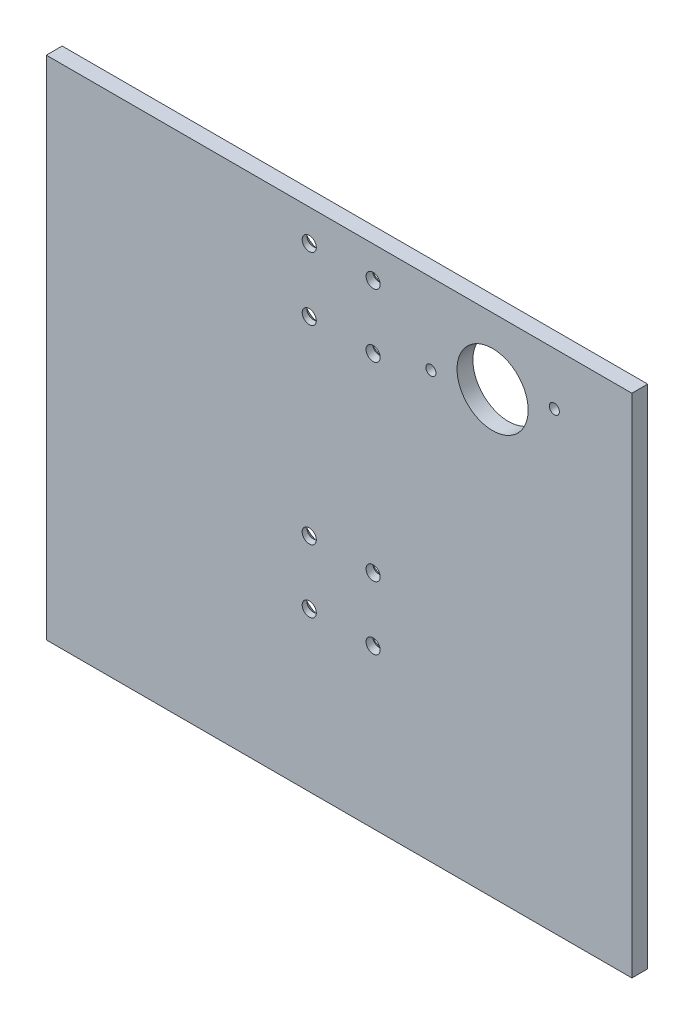
from build123d import *

# Parameters (mm, degrees)
SKETCH1_W                                          = 234.95
SKETCH1_H                                          = 203.2
BOSS_EXTRUDE1_DEPTH                                = 6.35
SKETCH2_R                                          = 14.2748
CUT_EXTRUDE1_DEPTH                                 = 7.35
CSK_FOR_10_FLAT_HEAD_MACHINE_SCREW_100_D           = 5.6134
CSK_FOR_10_FLAT_HEAD_MACHINE_SCREW_100_CSINK_D     = 17.78
CSK_FOR_10_FLAT_HEAD_MACHINE_SCREW_100_CSINK_ANGLE = 90
CSK_FOR_10_FLAT_HEAD_MACHINE_SCREW_2_D             = 5.6134
CSK_FOR_10_FLAT_HEAD_MACHINE_SCREW_2_CSINK_D       = 17.78
CSK_FOR_10_FLAT_HEAD_MACHINE_SCREW_2_CSINK_ANGLE   = 90
CUT_EXTRUDE2_DEPTH                                 = 7.35


with BuildPart() as part:
    # Sketch1 → Boss-Extrude1 (new body)
    with BuildSketch(Plane.XY):
        Rectangle(SKETCH1_W, SKETCH1_H)
    extrude(amount=BOSS_EXTRUDE1_DEPTH)

    # Sketch2 → Cut-Extrude1 (cut, through all)
    with BuildSketch(Plane.XY.offset(6.35)):
        with Locations((61.595, 74.93)):
            Circle(SKETCH2_R)
    extrude(amount=-CUT_EXTRUDE1_DEPTH, mode=Mode.SUBTRACT)

    # CSK for _10 Flat Head Machine Screw _100 (through all)
    with Locations(Plane(origin=(292.076985897, -265.595089466, -43.80037576), x_dir=(0.990861087, 0, -0.134886274), z_dir=(-0.134886274, 0, -0.990861087))):
        with Locations((-308.041854919, -227.495089466), (-308.041854919, -252.895089466), (-308.041972913, -329.095089466), (-308.041972913, -354.495089466)):
            CounterSinkHole(CSK_FOR_10_FLAT_HEAD_MACHINE_SCREW_100_D / 2, CSK_FOR_10_FLAT_HEAD_MACHINE_SCREW_100_CSINK_D / 2, counter_sink_angle=CSK_FOR_10_FLAT_HEAD_MACHINE_SCREW_100_CSINK_ANGLE)

    # CSK for _10 Flat Head Machine Screw  2 (through all)
    with Locations(Plane(origin=(292.419597033, -265.595089466, -41.283588599), x_dir=(0.990861087, 0, -0.134886274), z_dir=(-0.134886274, 0, -0.990861087))):
        with Locations((-282.641854919, -227.495089466), (-282.641854919, -252.895089466), (-282.641972913, -329.095089466), (-282.641972913, -354.495089466)):
            CounterSinkHole(CSK_FOR_10_FLAT_HEAD_MACHINE_SCREW_2_D / 2, CSK_FOR_10_FLAT_HEAD_MACHINE_SCREW_2_CSINK_D / 2, counter_sink_angle=CSK_FOR_10_FLAT_HEAD_MACHINE_SCREW_2_CSINK_ANGLE)

    # Sketch10 → Cut-Extrude2 (cut, through all)
    with BuildSketch(Plane(origin=(0, 0, 0), x_dir=(-1, 0, 0), z_dir=(0, 0, -1))):
        with BuildLine():
            ThreePointArc((-85.905304985, 82.561948902), (-88.324015931, 81.043732073), (-86.805799102, 78.625021127))
            ThreePointArc((-86.805799102, 78.625021127), (-84.387088156, 80.143237956), (-85.905304985, 82.561948902))
        make_face()
        with BuildLine():
            ThreePointArc((-36.384200898, 71.234978873), (-38.802911844, 69.716762044), (-37.284695016, 67.298051098))
            ThreePointArc((-37.284695016, 67.298051098), (-34.86598407, 68.816267927), (-36.384200898, 71.234978873))
        make_face()
    extrude(amount=-CUT_EXTRUDE2_DEPTH, mode=Mode.SUBTRACT)


solid = part.part
